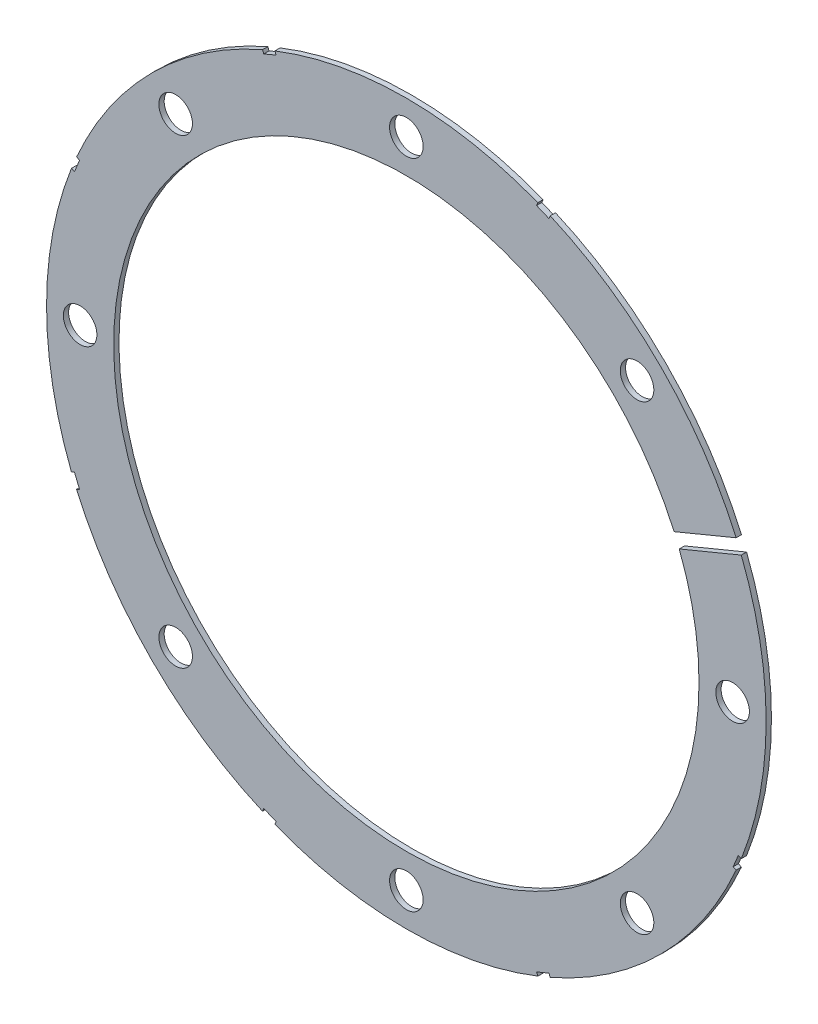
from build123d import *

# Parameters (mm, degrees)
SKETCH4_R           = 68.072
BOSS_EXTRUDE2_DEPTH = 1
SKETCH5_R           = 55.372
CUT_EXTRUDE5_DEPTH  = 2
SKETCH6_R           = 3.175
CUT_EXTRUDE6_DEPTH  = 2
CIRPATTERN1_COUNT   = 8
CUT_EXTRUDE11_DEPTH = 2


with BuildPart() as part:
    # Sketch4 → Boss-Extrude2 (new body)
    with BuildSketch(Plane.XY):
        Circle(SKETCH4_R)
    extrude(amount=BOSS_EXTRUDE2_DEPTH)

    # Sketch5 → Cut-Extrude5 (cut, through all)
    with BuildSketch(Plane.XY.offset(1)):
        Circle(SKETCH5_R)
    extrude(amount=-CUT_EXTRUDE5_DEPTH, mode=Mode.SUBTRACT)

    # Sketch6 → Cut-Extrude6 (cut, through all)
    with BuildSketch(Plane.XY.offset(1)):
        with Locations((61.722, 0)):
            Circle(SKETCH6_R)
    cut_extrude6 = extrude(amount=-CUT_EXTRUDE6_DEPTH, mode=Mode.SUBTRACT)

    # CirPattern1: Cut-Extrude6 ×8 about axis
    cirpattern1_axis = Axis((0, 0, 0), (0, 0, 1))
    for i in range(1, CIRPATTERN1_COUNT):
        add(cut_extrude6.rotate(cirpattern1_axis, i * 360 / CIRPATTERN1_COUNT), mode=Mode.SUBTRACT)

    # Sketch8 → Cut-Extrude11 (cut, through all)
    with BuildSketch(Plane.XY.offset(1)):
        Polygon((65.924300597, 28.681377492), (47.151068496, 20.905250146), (48.123084414, 18.558596133), (66.896316515, 26.334723479), align=None)
        Polygon((27.466357594, 62.990983081), (25.119703581, 63.962998999), (24.633695622, 62.789671993), (26.980349635, 61.817656075), align=None)
        Polygon((-25.119703581, 63.962998999), (-27.466357594, 62.990983081), (-26.980349635, 61.817656075), (-24.633695622, 62.789671993), align=None)
        Polygon((-62.990983081, 27.466357594), (-63.962998999, 25.119703581), (-62.789671993, 24.633695622), (-61.817656075, 26.980349635), align=None)
        Polygon((-63.962998999, -25.119703581), (-62.990983081, -27.466357594), (-61.817656075, -26.980349635), (-62.789671993, -24.633695622), align=None)
        Polygon((-27.466357594, -62.990983081), (-25.119703581, -63.962998999), (-24.633695622, -62.789671993), (-26.980349635, -61.817656075), align=None)
        Polygon((25.119703581, -63.962998999), (27.466357594, -62.990983081), (26.980349635, -61.817656075), (24.633695622, -62.789671993), align=None)
        Polygon((62.990983081, -27.466357594), (63.962998999, -25.119703581), (62.789671993, -24.633695622), (61.817656075, -26.980349635), align=None)
    extrude(amount=-CUT_EXTRUDE11_DEPTH, mode=Mode.SUBTRACT)


solid = part.part
